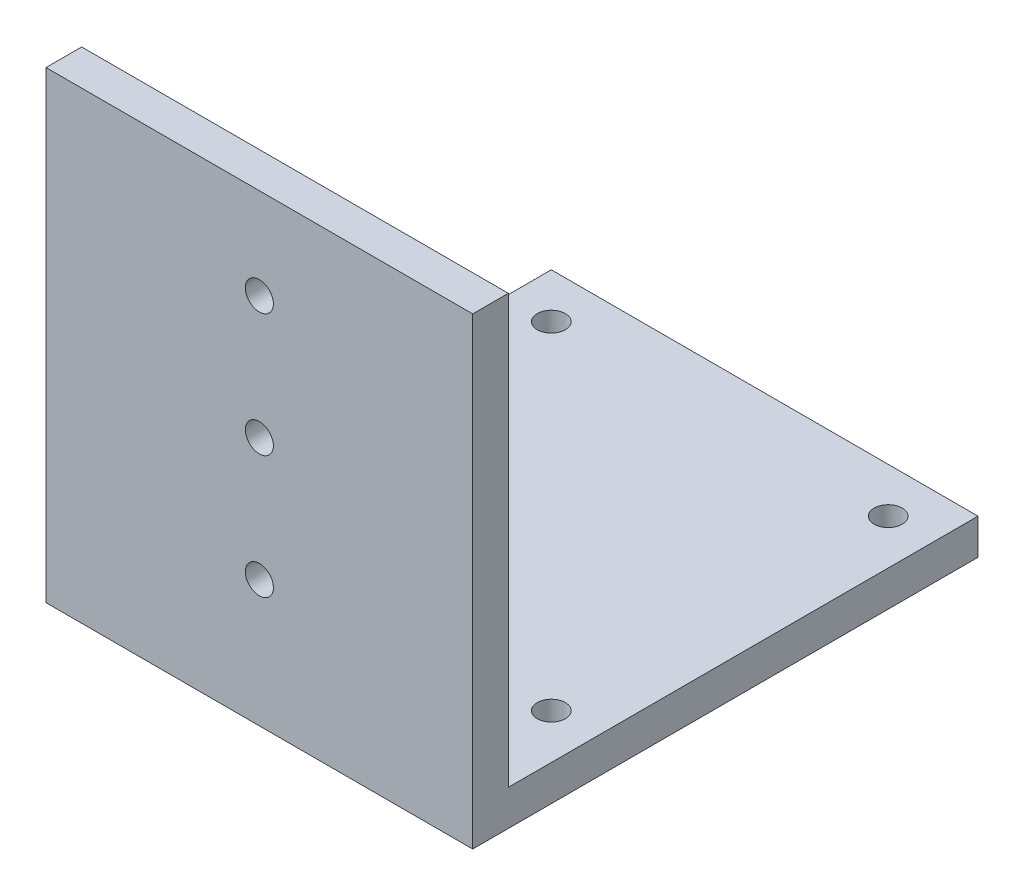
from build123d import *

# Parameters (mm, degrees)
SKETCH1_W            = 38
SKETCH1_H            = 45
BOSS_EXTRUDE1_DEPTH  = 3.175
SKETCH2_W            = 38
SKETCH2_H            = 3.175
BOSS_EXTRUDE2_DEPTH  = 38.1
SKETCH3_R            = 1.25
CAMERA_HOLES_DEPTH   = 10
SKETCH4_R            = 1.25
MOUNTING_HOLES_DEPTH = 10


with BuildPart() as part:
    # Sketch1 → Boss-Extrude1 (new body)
    with BuildSketch(Plane(origin=(0, 0, 0), x_dir=(1, 0, 0), z_dir=(0, 1, 0))):
        with Locations((19, -22.5)):
            Rectangle(SKETCH1_W, SKETCH1_H)
    extrude(amount=BOSS_EXTRUDE1_DEPTH)

    # Sketch2 → Boss-Extrude2 (add)
    with BuildSketch(Plane(origin=(0, 3.175, 0), x_dir=(1, 0, 0), z_dir=(0, 1, 0))):
        with Locations((19, -43.4125)):
            Rectangle(SKETCH2_W, SKETCH2_H)
    extrude(amount=BOSS_EXTRUDE2_DEPTH)

    # Sketch3 → camera holes (cut)
    with BuildSketch(Plane.XZ):
        with Locations((4, 34)):
            Circle(SKETCH3_R)
        with Locations((34, 34)):
            Circle(SKETCH3_R)
        with Locations((4, 4)):
            Circle(SKETCH3_R)
        with Locations((34, 4)):
            Circle(SKETCH3_R)
    extrude(amount=-CAMERA_HOLES_DEPTH, mode=Mode.SUBTRACT)

    # Sketch4 → mounting holes (cut)
    with BuildSketch(Plane.XY.offset(45)):
        with Locations((19, 11.28125)):
            Circle(SKETCH4_R)
        with Locations((19, 33.16875)):
            Circle(SKETCH4_R)
        with Locations((19, 22.225)):
            Circle(SKETCH4_R)
    extrude(amount=-MOUNTING_HOLES_DEPTH, mode=Mode.SUBTRACT)


solid = part.part
